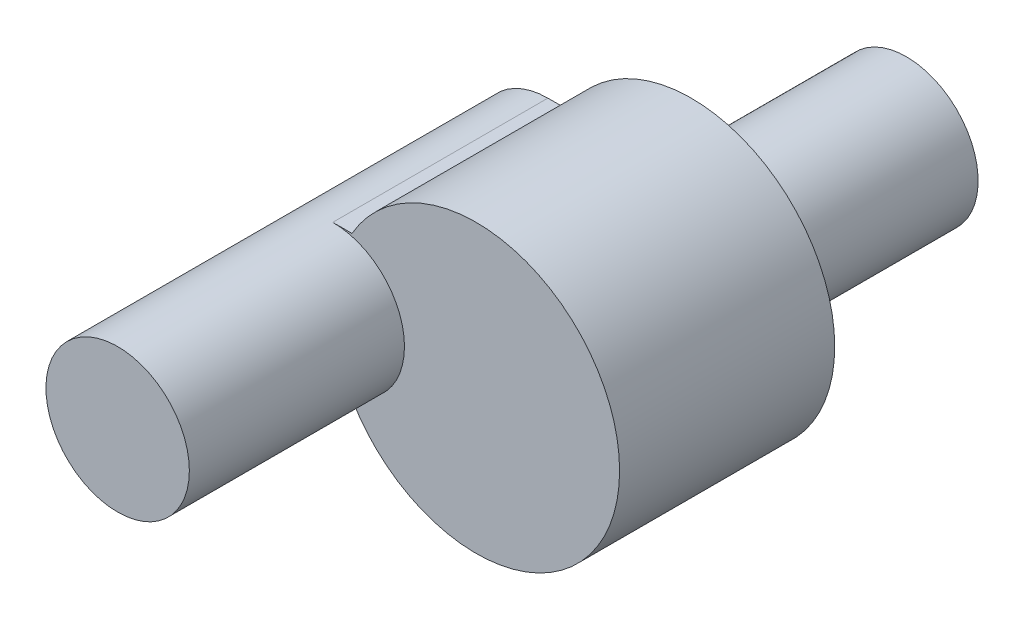
from build123d import *

# Parameters (mm, degrees)
BOSS_EXTRUDE1_DEPTH = 3
SKETCH2_R           = 1
BOSS_EXTRUDE2_DEPTH = 3
SKETCH3_R           = 1
BOSS_EXTRUDE3_DEPTH = 3


with BuildPart() as part:
    # Sketch1 → Boss-Extrude1 (new body)
    with BuildSketch(Plane.XY):
        with BuildLine():
            ThreePointArc((-8.470745652, 3.390391994), (-4.738694844, 4.390391994), (-8.470745652, 5.390391994))
            Line((-8.470745652, 5.390391994), (-8.738694844, 5.390391994))
            ThreePointArc((-8.738694844, 5.390391994), (-9.738694844, 4.390391994), (-8.738694844, 3.390391994))
            Line((-8.738694844, 3.390391994), (-8.470745652, 3.390391994))
        make_face()
    extrude(amount=BOSS_EXTRUDE1_DEPTH)

    # Sketch2 → Boss-Extrude2 (add)
    with BuildSketch(Plane.XY.offset(3)):
        with Locations((-8.738694844, 4.390391994)):
            Circle(SKETCH2_R)
    extrude(amount=BOSS_EXTRUDE2_DEPTH)

    # Sketch3 → Boss-Extrude3 (add)
    with BuildSketch(Plane(origin=(0, 0, 0), x_dir=(-1, 0, 0), z_dir=(0, 0, -1))):
        with Locations((6.738694844, 4.390391994)):
            Circle(SKETCH3_R)
    extrude(amount=BOSS_EXTRUDE3_DEPTH)


solid = part.part
